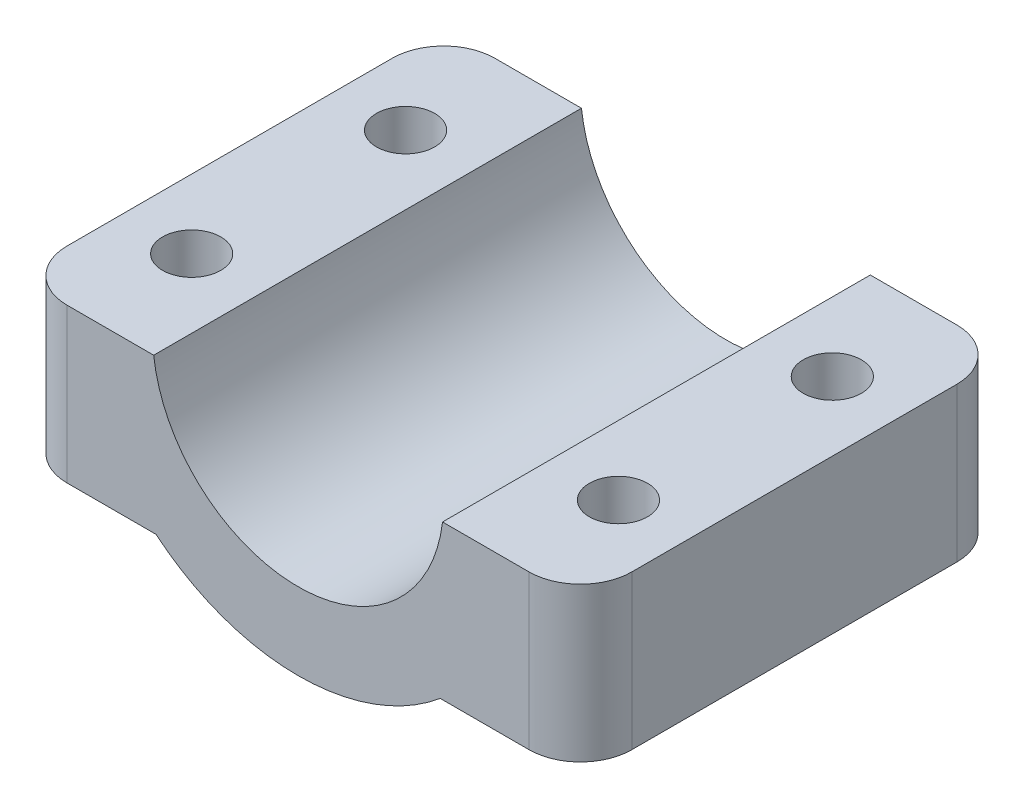
from build123d import *

# Parameters (mm, degrees)
SALIENTE_EXTRUIR1_DEPTH = 12.5
CROQUIS2_R              = 1.7
CORTAR_EXTRUIR1_DEPTH   = 9
CROQUIS6_R              = 3.1
CORTAR_EXTRUIR4_DEPTH   = 3
REDONDEO1_R             = 3


with BuildPart() as part:
    # Croquis1 → Saliente-Extruir1 (new body, symmetric)
    with BuildSketch(Plane.XY):
        with BuildLine():
            Line((-16.5, 7.5), (-8.440971508, 7.5))
            ThreePointArc((-8.440971508, 7.5), (0, 0), (8.440971508, 7.5))
            Line((8.440971508, 7.5), (16.5, 7.5))
            Line((16.5, 7.5), (16.5, -1.5))
            Line((16.5, -1.5), (8.306623863, -1.5))
            ThreePointArc((8.306623863, -1.5), (0, -4.5), (-8.306623863, -1.5))
            Line((-8.306623863, -1.5), (-16.5, -1.5))
            Line((-16.5, -1.5), (-16.5, 7.5))
        make_face()
    extrude(amount=SALIENTE_EXTRUIR1_DEPTH, both=True)

    # Croquis2 → Cortar-Extruir1 (cut)
    with BuildSketch(Plane(origin=(0, 7.5, 0), x_dir=(1, 0, 0), z_dir=(0, 1, 0))):
        with Locations((-12.470485754, 6.25)):
            Circle(CROQUIS2_R)
        with Locations((12.470485754, 6.25)):
            Circle(CROQUIS2_R)
        with Locations((12.470485754, -6.25)):
            Circle(CROQUIS2_R)
        with Locations((-12.470485754, -6.25)):
            Circle(CROQUIS2_R)
    extrude(amount=-CORTAR_EXTRUIR1_DEPTH, mode=Mode.SUBTRACT)

    # Croquis6 → Cortar-Extruir4 (cut)
    with BuildSketch(Plane.XZ.offset(1.5)):
        with Locations((-12.470485754, 6.25)):
            Circle(CROQUIS6_R)
        with Locations((12.470485754, 6.25)):
            Circle(CROQUIS6_R)
        with Locations((12.470485754, -6.25)):
            Circle(CROQUIS6_R)
        with Locations((-12.470485754, -6.25)):
            Circle(CROQUIS6_R)
    extrude(amount=-CORTAR_EXTRUIR4_DEPTH, mode=Mode.SUBTRACT)

    # Redondeo1
    redondeo1_edges = [part.edges().sort_by_distance(p)[0] for p in [
        (16.5, 3, -12.5),
        (-16.5, 3, 12.5),
        (16.5, 3, 12.5),
        (-16.5, 3, -12.5),
    ]]
    fillet(redondeo1_edges, radius=REDONDEO1_R)


solid = part.part
